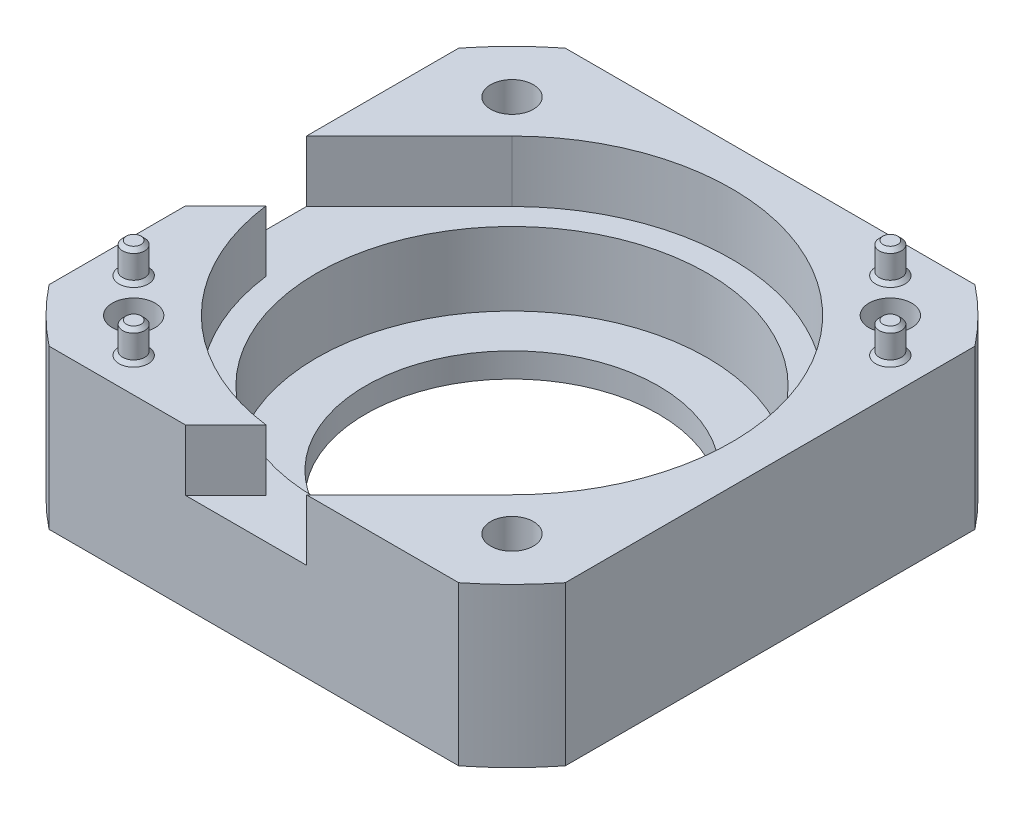
from build123d import *

# Parameters (mm, degrees)
SKETCH2_W           = 42.3
SKETCH2_H           = 42.3
BOSS_EXTRUDE1_DEPTH = 13
SKETCH3_R           = 11
CUT_EXTRUDE1_DEPTH  = 14
SKETCH4_R           = 1.75
CUT_EXTRUDE2_DEPTH  = 14
SKETCH5_R           = 29.910616844
SKETCH5_R_2         = 27
CUT_EXTRUDE4_DEPTH  = 14
CUT_EXTRUDE5_DEPTH  = 11
SKETCH7_R           = 16
BOSS_EXTRUDE2_DEPTH = 6
SKETCH8_R           = 0.9
BOSS_EXTRUDE3_DEPTH = 2.5
CHAMFER1_SIZE       = 0.3
CHAMFER2_SIZE       = 0.3
SKETCH9_R           = 12
CUT_EXTRUDE6_DEPTH  = 3
CHAMFER4_SIZE       = 0.5


with BuildPart() as part:
    # Sketch2 → Boss-Extrude1 (new body)
    with BuildSketch(Plane(origin=(0, 0, 0), x_dir=(1, 0, 0), z_dir=(0, 1, 0))):
        Rectangle(SKETCH2_W, SKETCH2_H)
    extrude(amount=BOSS_EXTRUDE1_DEPTH)

    # Sketch3 → Cut-Extrude1 (cut, through all)
    with BuildSketch(Plane(origin=(0, 13, 0), x_dir=(1, 0, 0), z_dir=(0, 1, 0))):
        Circle(SKETCH3_R)
    extrude(amount=-CUT_EXTRUDE1_DEPTH, mode=Mode.SUBTRACT)

    # Sketch4 → Cut-Extrude2 (cut, through all)
    with BuildSketch(Plane(origin=(0, 13, 0), x_dir=(1, 0, 0), z_dir=(0, 1, 0))):
        with Locations((-15.5, 15.5)):
            Circle(SKETCH4_R)
        with Locations((15.5, 15.5)):
            Circle(SKETCH4_R)
        with Locations((15.5, -15.5)):
            Circle(SKETCH4_R)
        with Locations((-15.5, -15.5)):
            Circle(SKETCH4_R)
    extrude(amount=-CUT_EXTRUDE2_DEPTH, mode=Mode.SUBTRACT)

    # Sketch5 → Cut-Extrude4 (cut, through all)
    with BuildSketch(Plane(origin=(0, 13, 0), x_dir=(1, 0, 0), z_dir=(0, 1, 0))):
        Circle(SKETCH5_R)
        Circle(SKETCH5_R_2, mode=Mode.SUBTRACT)
    extrude(amount=-CUT_EXTRUDE4_DEPTH, mode=Mode.SUBTRACT)

    # Sketch6 → Cut-Extrude5 (cut)
    with BuildSketch(Plane(origin=(0, 13, 0), x_dir=(1, 0, 0), z_dir=(0, 1, 0))):
        with BuildLine():
            Line((-21.15, 4.305844123), (-12.727922061, 12.727922061))
            ThreePointArc((-12.727922061, 12.727922061), (12.727922061, 12.727922061), (12.727922061, -12.727922061))
            Line((12.727922061, -12.727922061), (4.305844123, -21.15))
            Line((4.305844123, -21.15), (-5.593650814, -21.15))
            Line((-5.593650814, -21.15), (-2.296546247, -17.852895433))
            ThreePointArc((-2.296546247, -17.852895433), (-12.727922061, -12.727922061), (-17.852895433, -2.296546247))
            Line((-17.852895433, -2.296546247), (-21.15, -5.593650814))
            Line((-21.15, -5.593650814), (-21.15, 4.305844123))
        make_face()
    extrude(amount=-CUT_EXTRUDE5_DEPTH, mode=Mode.SUBTRACT)

    # Sketch7 → Boss-Extrude2 (add)
    with BuildSketch(Plane(origin=(0, 2, 0), x_dir=(1, 0, 0), z_dir=(0, 1, 0))):
        with BuildLine():
            Line((-21.15, 4.305844123), (-21.15, -5.593650814))
            Line((-21.15, -5.593650814), (-17.852895433, -2.296546247))
            ThreePointArc((-17.852895433, -2.296546247), (-12.727922061, -12.727922061), (-2.296546247, -17.852895433))
            Line((-2.296546247, -17.852895433), (-5.593650814, -21.15))
            Line((-5.593650814, -21.15), (4.305844123, -21.15))
            Line((4.305844123, -21.15), (12.727922061, -12.727922061))
            ThreePointArc((12.727922061, -12.727922061), (12.727922061, 12.727922061), (-12.727922061, 12.727922061))
            Line((-12.727922061, 12.727922061), (-21.15, 4.305844123))
        make_face()
        Circle(SKETCH7_R, mode=Mode.SUBTRACT)
    extrude(amount=BOSS_EXTRUDE2_DEPTH)

    # Sketch8 → Boss-Extrude3 (add)
    with BuildSketch(Plane(origin=(0, 13, 0), x_dir=(1, 0, 0), z_dir=(0, 1, 0))):
        with Locations((12.671572875, 18.328427125)):
            Circle(SKETCH8_R)
        with Locations((18.328427125, 12.671572875)):
            Circle(SKETCH8_R)
        with Locations((-12.671572875, -18.328427125)):
            Circle(SKETCH8_R)
        with Locations((-18.328427125, -12.671572875)):
            Circle(SKETCH8_R)
    extrude(amount=BOSS_EXTRUDE3_DEPTH)

    # Chamfer1
    chamfer1_edges = [part.edges().sort_by_distance(p)[0] for p in [
        (11.771572875, 15.5, -18.328427125),
        (17.428427125, 15.5, -12.671572875),
        (-13.571572875, 15.5, 18.328427125),
        (-19.228427125, 15.5, 12.671572875),
    ]]
    chamfer(chamfer1_edges, length=CHAMFER1_SIZE)

    # Chamfer2
    chamfer2_edges = [part.edges().sort_by_distance(p)[0] for p in [
        (11.771572875, 13, -18.328427125),
        (17.428427125, 13, -12.671572875),
        (-13.571572875, 13, 18.328427125),
        (-19.228427125, 13, 12.671572875),
    ]]
    chamfer(chamfer2_edges, length=CHAMFER2_SIZE)

    # Sketch9 → Cut-Extrude6 (cut, through all)
    with BuildSketch(Plane(origin=(0, 2, 0), x_dir=(1, 0, 0), z_dir=(0, 1, 0))):
        Circle(SKETCH9_R)
    extrude(amount=-CUT_EXTRUDE6_DEPTH, mode=Mode.SUBTRACT)

    # Chamfer4
    chamfer4_edges = [part.edges().sort_by_distance(p)[0] for p in [
        (-17.25, 0, 15.5),
        (13.75, 0, 15.5),
        (13.75, 0, -15.5),
        (-17.25, 0, -15.5),
    ]]
    chamfer(chamfer4_edges, length=CHAMFER4_SIZE)


solid = part.part
